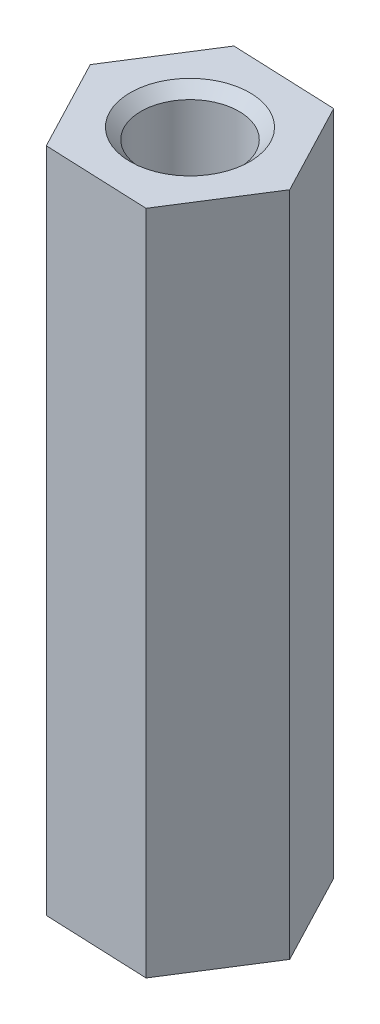
from build123d import *

# Parameters (mm, degrees)
SKETCH_1_R                   = 1.1
EXTRUDE_1_DEPTH              = 17
HOLE_WIZARD_M3_2_D           = 2.5
HOLE_WIZARD_M3_2_CSINK_D     = 3.05
HOLE_WIZARD_M3_2_CSINK_ANGLE = 90


with BuildPart() as part:
    # 草图1 → 凸台-拉伸1 (new body)
    with BuildSketch(Plane(origin=(0, 0, 0), x_dir=(1, 0, 0), z_dir=(0, 1, 0))):
        Polygon((1.231724884, -2.352910356), (2.653542583, -0.109750138), (1.421817699, 2.243160218), (-1.231724884, 2.352910356), (-2.653542583, 0.109750138), (-1.421817699, -2.243160218), align=None)
        Circle(SKETCH_1_R, mode=Mode.SUBTRACT)
    extrude(amount=EXTRUDE_1_DEPTH)

    # M3 螺纹孔2 (through all)
    with Locations(Plane(origin=(0, 17, 0), x_dir=(1, 0, 0), z_dir=(0, 1, 0))):
        with Locations((0, 0)):
            CounterSinkHole(HOLE_WIZARD_M3_2_D / 2, HOLE_WIZARD_M3_2_CSINK_D / 2, counter_sink_angle=HOLE_WIZARD_M3_2_CSINK_ANGLE)


solid = part.part
